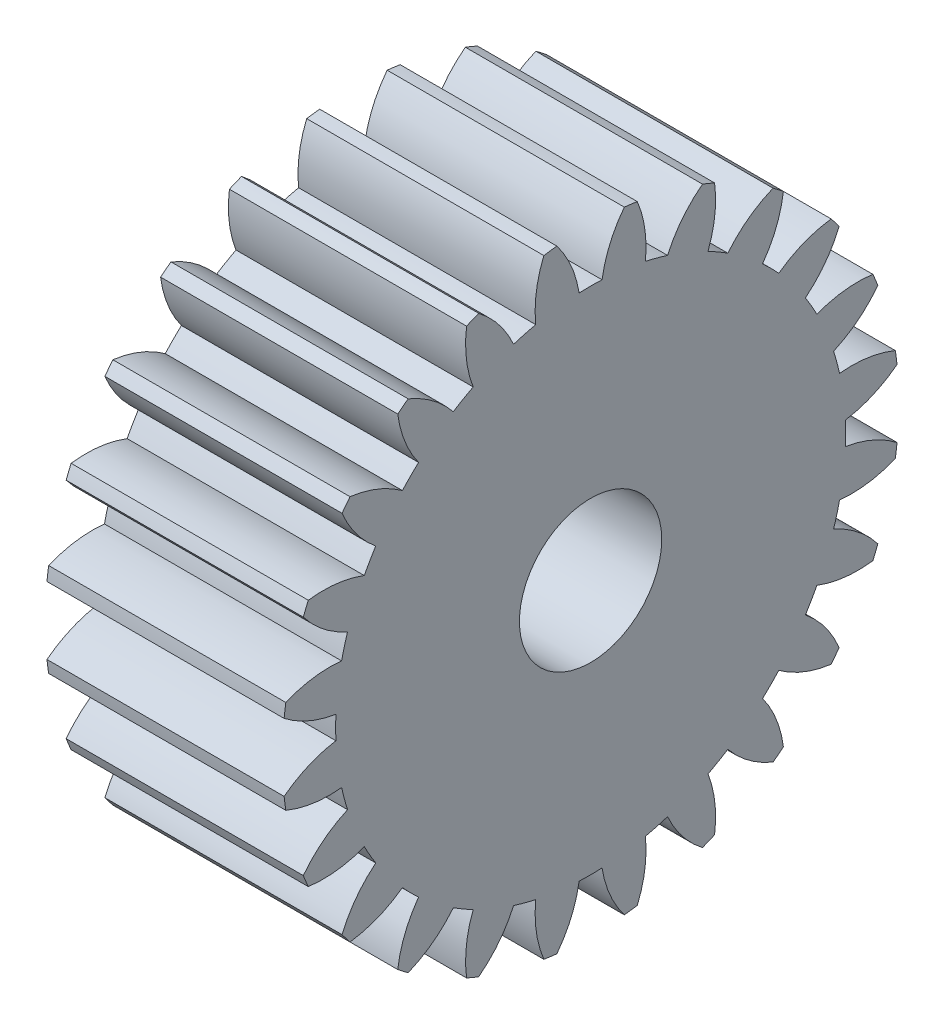
from build123d import *

# Parameters (mm, degrees)
BASPROSKE_W        = 10
BASPROSKE_H        = 13
TOOTHCUT_DEPTH     = 21.928449536
TEETHCUTS_COUNT    = 24
TEETHCUTS_ANGLE    = 345
BORSKE_R           = 2.5
BORE_DEPTH         = 50.0000508
SKETCH1_R          = 3
CUT_EXTRUDE1_DEPTH = 21.83151436


with BuildPart() as part:
    # BasProSke → Base-Revolve (revolve)
    with BuildSketch(Plane(origin=(0, 0, 0), x_dir=(1, 0, 0), z_dir=(0, 1, 0)), mode=Mode.PRIVATE) as base_revolve_sk:
        with Locations((5, 6.5)):
            Rectangle(BASPROSKE_W, BASPROSKE_H)
    revolve(base_revolve_sk.sketch.rotate(Axis((-10, 0, 0), (1, 0, 0)), 180), axis=Axis((-10, 0, 0), (1, 0, 0)))

    # TooCutSke → ToothCut (cut, through all)
    with BuildSketch(Plane(origin=(0, 0, 0), x_dir=(0, 0, -1), z_dir=(1, 0, 0))):
        with BuildLine():
            ThreePointArc((0.483448384, 10.738122679), (0, 10.749), (-0.483448384, 10.738122679))
            ThreePointArc((-0.483448384, 10.738122679), (-0.821636462, 11.902754369), (-1.44092227, 12.945454344))
            ThreePointArc((-1.44092227, 12.945454344), (0, 13.0254), (1.44092227, 12.945454344))
            ThreePointArc((1.44092227, 12.945454344), (0.821636462, 11.902754369), (0.483448384, 10.738122679))
        make_face()
    toothcut = extrude(amount=TOOTHCUT_DEPTH, mode=Mode.SUBTRACT)

    # TeethCuts: ToothCut ×24 about axis
    teethcuts_axis = Axis((-10, 0, 0), (1, 0, 0))
    for i in range(1, TEETHCUTS_COUNT):
        add(toothcut.rotate(teethcuts_axis, i * TEETHCUTS_ANGLE / (TEETHCUTS_COUNT - 1)), mode=Mode.SUBTRACT)

    # BorSke → Bore (cut, symmetric)
    with BuildSketch(Plane(origin=(0, 0, 0), x_dir=(0, 0, -1), z_dir=(1, 0, 0))):
        with Locations(Location((0, 0, 0), (0, 0, 180))):
            Circle(BORSKE_R)
    extrude(amount=BORE_DEPTH, both=True, mode=Mode.SUBTRACT)

    # Sketch1 → Cut-Extrude1 (cut, through all)
    with BuildSketch(Plane(origin=(10, 0, 0), x_dir=(0, 0, -1), z_dir=(1, 0, 0))):
        Circle(SKETCH1_R)
    extrude(amount=-CUT_EXTRUDE1_DEPTH, mode=Mode.SUBTRACT)


solid = part.part
